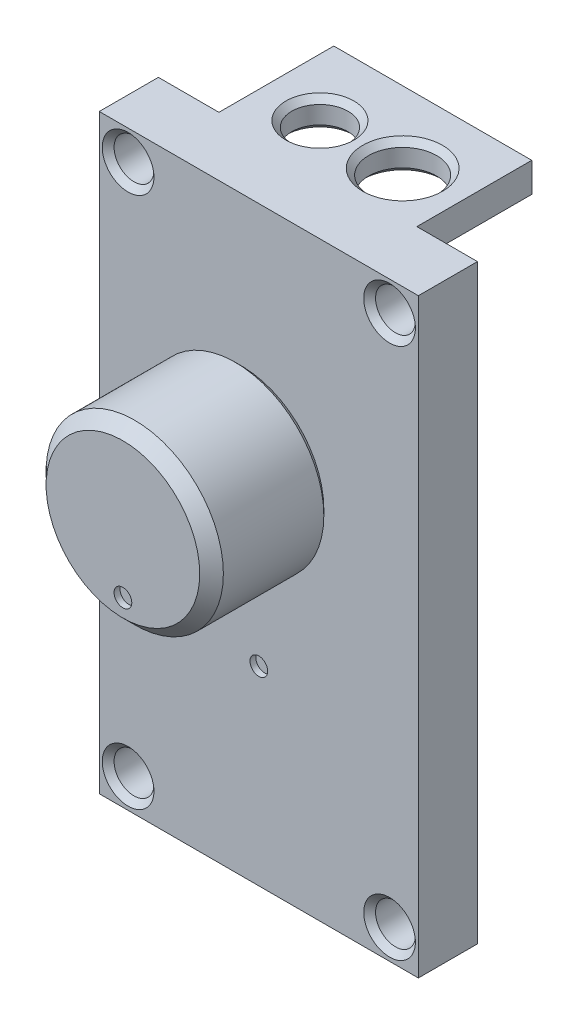
from build123d import *

# Parameters (mm, degrees)
SKETCH1_W                                   = 54
SKETCH1_H                                   = 100
BOSS_EXTRUDE1_DEPTH                         = 10
SKETCH2_R                                   = 15
BOSS_EXTRUDE2_DEPTH                         = 20
CUT_EXTRUDE1_DEPTH                          = 11
CHAMFER1_SIZE                               = 2
SKETCH5_R                                   = 1.5
CUT_EXTRUDE2_DEPTH                          = 1
CHAMFER2_SIZE                               = 1
SKETCH6_R                                   = 12.5
CUT_EXTRUDE3_DEPTH                          = 15.5
FILLET1_R                                   = 1
SKETCH7_R                                   = 1.5
CUT_EXTRUDE4_DEPTH                          = 1
BOSS_EXTRUDE3_DEPTH                         = 5
CBORE_FOR_4_BINDING_HEAD_MACHINE_SC_2_COUNT = 2
CBORE_FOR_4_BINDING_HEAD_MACHINE_SC_2_PITCH = 44.25
CBORE_FOR_4_BINDING_HEAD_MACHINE_SC_3_COUNT = 2
CBORE_FOR_4_BINDING_HEAD_MACHINE_SC_3_PITCH = 100.289892312
CBORE_FOR_4_BINDING_HEAD_MACHINE_SC_4_COUNT = 2
CBORE_FOR_4_BINDING_HEAD_MACHINE_SC_4_PITCH = 90
SKETCH11_R                                  = 5.75
SKETCH11_R_2                                = 4.75
CUT_EXTRUDE5_DEPTH                          = 5
CHAMFER4_SIZE                               = 1
CUT_EXTRUDE6_DEPTH                          = 8.5
CHAMFER6_SIZE                               = 1
SKETCH13_W                                  = 11.7943465
SKETCH13_H                                  = 9.696483865
CUT_EXTRUDE7_DEPTH                          = 3
CHAMFER7_SIZE                               = 0.5
SKETCH14_W                                  = 1
SKETCH14_H                                  = 12.993349563
CUT_EXTRUDE8_DEPTH                          = 7


with BuildPart() as part:
    # Sketch1 → Boss-Extrude1 (new body)
    with BuildSketch(Plane.XY):
        with Locations((-1.910911092, -7.023806668)):
            Rectangle(SKETCH1_W, SKETCH1_H)
        with BuildLine():
            Line((-3.972463905, 10.726193332), (0.150641721, 10.726193332))
            ThreePointArc((0.150641721, 10.726193332), (1.271069424, 9.908173847), (2.089088908, 8.787746145))
            Line((2.089088908, 8.787746145), (2.089088908, 4.664640519))
            ThreePointArc((2.089088908, 4.664640519), (1.271069424, 3.544212817), (0.150641721, 2.726193332))
            Line((0.150641721, 2.726193332), (-3.972463905, 2.726193332))
            ThreePointArc((-3.972463905, 2.726193332), (-5.092891607, 3.544212817), (-5.910911092, 4.664640519))
            Line((-5.910911092, 4.664640519), (-5.910911092, 8.787746145))
            ThreePointArc((-5.910911092, 8.787746145), (-5.092891607, 9.908173847), (-3.972463905, 10.726193332))
        make_face(mode=Mode.SUBTRACT)
    extrude(amount=BOSS_EXTRUDE1_DEPTH)

    # Sketch7 → Cut-Extrude4 (cut)
    with BuildSketch(Plane.XY.offset(10)):
        with Locations((-1.910911092, -24.822609261)):
            Circle(SKETCH7_R)
    extrude(amount=-CUT_EXTRUDE4_DEPTH, mode=Mode.SUBTRACT)

    # Sketch8 → Boss-Extrude3 (add)
    with BuildSketch(Plane(origin=(0, 42.976193332, 0), x_dir=(1, 0, 0), z_dir=(0, 1, 0))):
        Polygon((-18.660911092, 0.5), (-18.660911092, 0), (14.839088908, 0), (14.839088908, 0.5), (14.839088908, 19.438), (-18.660911092, 19.438), align=None)
    extrude(amount=-BOSS_EXTRUDE3_DEPTH)

    # Sketch9 → CBORE for _4 Binding Head Machine Screw1 (revolve, cut)
    with BuildSketch(Plane(origin=(20.214088908, -52.023806668, 10), x_dir=(0, -1, 0), z_dir=(1, 0, 0))):
        Polygon((0, 0), (0, 29.438025), (1.63195, 29.438025), (1.63195, 7.727188), (3.37312, 7.727188), (3.37312, 0), align=None)
    cbore_for_4_binding_head_machine_screw1 = revolve(axis=Axis((20.214088908, -52.023806668, 16.35), (0, 0, -1)), mode=Mode.SUBTRACT)

    # CBORE for _4 Binding Head Machine Sc 2: CBORE for _4 Binding Head Machine Screw1 ×2
    with Locations(*[(-i * CBORE_FOR_4_BINDING_HEAD_MACHINE_SC_2_PITCH, 0, 0) for i in range(1, CBORE_FOR_4_BINDING_HEAD_MACHINE_SC_2_COUNT)]):
        add(cbore_for_4_binding_head_machine_screw1, mode=Mode.SUBTRACT)

    # CBORE for _4 Binding Head Machine Sc 3: CBORE for _4 Binding Head Machine Screw1 ×2
    with Locations(*[Vector(-0.441220934, 0.897398511, 0) * (i * CBORE_FOR_4_BINDING_HEAD_MACHINE_SC_3_PITCH) for i in range(1, CBORE_FOR_4_BINDING_HEAD_MACHINE_SC_3_COUNT)]):
        add(cbore_for_4_binding_head_machine_screw1, mode=Mode.SUBTRACT)

    # CBORE for _4 Binding Head Machine Sc 4: CBORE for _4 Binding Head Machine Screw1 ×2
    with Locations(*[(0, i * CBORE_FOR_4_BINDING_HEAD_MACHINE_SC_4_PITCH, 0) for i in range(1, CBORE_FOR_4_BINDING_HEAD_MACHINE_SC_4_COUNT)]):
        add(cbore_for_4_binding_head_machine_screw1, mode=Mode.SUBTRACT)

    # Sketch11 → Cut-Extrude5 (cut)
    with BuildSketch(Plane(origin=(0, 42.976193332, 0), x_dir=(1, 0, 0), z_dir=(0, 1, 0))):
        with Locations((5.089088908, 7.339044891)):
            Circle(SKETCH11_R)
        with Locations((-8.910911092, 7.339044891)):
            Circle(SKETCH11_R_2)
    extrude(amount=-CUT_EXTRUDE5_DEPTH, mode=Mode.SUBTRACT)

    # Chamfer4
    chamfer4_edges = [part.edges().sort_by_distance(p)[0] for p in [
        (-13.660911092, 42.976193332, -7.339044891),
        (-13.660911092, 37.976193332, -7.339044891),
        (-0.660911092, 42.976193332, -7.339044891),
        (-0.660911092, 37.976193332, -7.339044891),
    ]]
    chamfer(chamfer4_edges, length=CHAMFER4_SIZE)

    # Sketch12 → Cut-Extrude6 (cut)
    with BuildSketch(Plane(origin=(0, 0, 0), x_dir=(-1, 0, 0), z_dir=(0, 0, -1))):
        Polygon((-16.089088908, 28.976193332), (-16.089088908, 34.976193332), (19.910911092, 34.976193332), (19.910911092, 28.976193332), (19.910911092, -48.023806668), (-16.089088908, -48.023806668), align=None)
    extrude(amount=-CUT_EXTRUDE6_DEPTH, mode=Mode.SUBTRACT)

    # Chamfer6
    chamfer6_edges = [part.edges().sort_by_distance(p)[0] for p in [
        (20.214088908, 41.349313332, 10),
        (-24.035911092, 41.349313332, 10),
        (-24.035911092, -48.650686668, 10),
        (20.214088908, -48.650686668, 10),
    ]]
    chamfer(chamfer6_edges, length=CHAMFER6_SIZE)


with BuildPart() as body_2:
    # Sketch2 → Boss-Extrude2 (new body)
    with BuildSketch(Plane.XY.offset(13)):
        with Locations((-1.910911092, 6.726193332)):
            Circle(SKETCH2_R)
    extrude(amount=BOSS_EXTRUDE2_DEPTH)

    # Sketch2_3 → Cut-Extrude1 (cut)
    with BuildSketch(Plane.XY.offset(13)):
        with BuildLine():
            Line((0.915747713, 8.226193332), (-4.737569897, 8.226193332))
            ThreePointArc((-4.737569897, 8.226193332), (-1.910911092, 3.526193332), (0.915747713, 8.226193332))
        make_face()
    extrude(amount=CUT_EXTRUDE1_DEPTH, mode=Mode.SUBTRACT)

    # Chamfer1
    chamfer1_edges = [body_2.edges().sort_by_distance(p)[0] for p in [
        (-16.910911092, 6.726193332, 33),
    ]]
    chamfer(chamfer1_edges, length=CHAMFER1_SIZE)

    # Sketch5 → Cut-Extrude2 (cut)
    with BuildSketch(Plane.XY.offset(33)):
        with Locations((-1.910911092, -3.273806668)):
            Circle(SKETCH5_R)
    extrude(amount=-CUT_EXTRUDE2_DEPTH, mode=Mode.SUBTRACT)

    # Chamfer2
    chamfer2_edges = [body_2.edges().sort_by_distance(p)[0] for p in [
        (-16.910911092, 6.726193332, 13),
        (-1.910911092, 8.226193332, 13),
        (-1.910911092, 3.526193332, 13),
    ]]
    chamfer(chamfer2_edges, length=CHAMFER2_SIZE)

    # Sketch6 → Cut-Extrude3 (cut)
    with BuildSketch(Plane(origin=(0, 0, 13), x_dir=(-1, 0, 0), z_dir=(0, 0, -1))):
        with Locations((1.910911092, 6.726193332)):
            Circle(SKETCH6_R)
        with BuildLine():
            Line((-1.707099411, 9.726193332), (5.528921595, 9.726193332))
            ThreePointArc((5.528921595, 9.726193332), (1.910911092, 2.026193332), (-1.707099411, 9.726193332))
        make_face(mode=Mode.SUBTRACT)
    extrude(amount=-CUT_EXTRUDE3_DEPTH, mode=Mode.SUBTRACT)

    # Fillet1
    fillet1_edges = [body_2.edges().sort_by_distance(p)[0] for p in [
        (10.589088908, 6.726193332, 28.5),
        (-1.910911092, 9.726193332, 28.5),
        (-1.910911092, 2.026193332, 28.5),
    ]]
    fillet(fillet1_edges, radius=FILLET1_R)

    # Sketch13 → Cut-Extrude7 (cut)
    with BuildSketch(Plane(origin=(0, 0, 13), x_dir=(-1, 0, 0), z_dir=(0, 0, -1))):
        with Locations((2.142085077, 4.8779514)):
            Rectangle(SKETCH13_W, SKETCH13_H)
    extrude(amount=-CUT_EXTRUDE7_DEPTH, mode=Mode.SUBTRACT)

    # Chamfer7
    chamfer7_edges = [body_2.edges().sort_by_distance(p)[0] for p in [
        (-1.910911092, 8.226193332, 16),
        (-1.910911092, 3.526193332, 16),
    ]]
    chamfer(chamfer7_edges, length=CHAMFER7_SIZE)

    # Sketch14 → Cut-Extrude8 (cut)
    with BuildSketch(Plane(origin=(0, 0, 16), x_dir=(-1, 0, 0), z_dir=(0, 0, -1))):
        with Locations((1.910911092, 6.039844616)):
            Rectangle(SKETCH14_W, SKETCH14_H)
    extrude(amount=-CUT_EXTRUDE8_DEPTH, mode=Mode.SUBTRACT)


solid = Compound([part.part, body_2.part])
